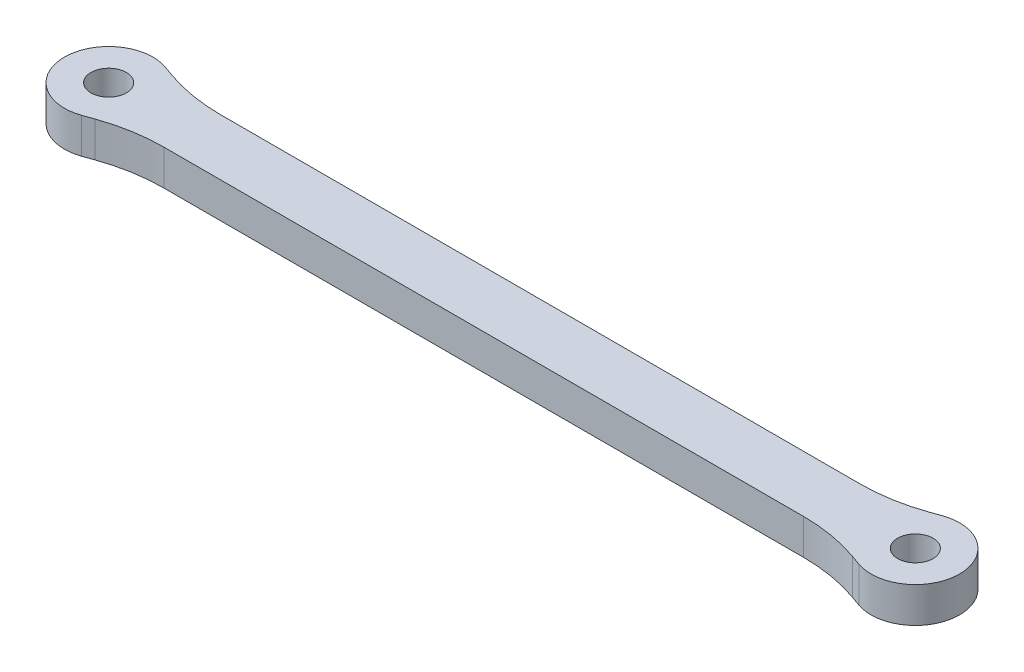
from build123d import *

# Parameters (mm, degrees)
SKETCH1_R           = 1
BOSS_EXTRUDE2_DEPTH = 2
FILLET2_R           = 10


with BuildPart() as part:
    # Sketch1 → Boss-Extrude2 (new body)
    with BuildSketch(Plane(origin=(0, 0, 0), x_dir=(1, 0, 0), z_dir=(0, 1, 0))):
        with BuildLine():
            Line((0.833333333, 2.357022604), (3.0003558, 1.590864463))
            Line((3.0003558, 1.590864463), (42.4996442, 1.590864463))
            Line((42.4996442, 1.590864463), (44.666666667, 2.357022604))
            ThreePointArc((44.666666667, 2.357022604), (48, 0), (44.666666667, -2.357022604))
            Line((44.666666667, -2.357022604), (42.4996442, -1.590864463))
            Line((42.4996442, -1.590864463), (3.0003558, -1.590864463))
            Line((3.0003558, -1.590864463), (0.833333333, -2.357022604))
            ThreePointArc((0.833333333, -2.357022604), (-2.5, 0), (0.833333333, 2.357022604))
        make_face()
        Circle(SKETCH1_R, mode=Mode.SUBTRACT)
        with Locations((45.5, 0)):
            Circle(SKETCH1_R, mode=Mode.SUBTRACT)
    extrude(amount=BOSS_EXTRUDE2_DEPTH)

    # Fillet2
    fillet2_edges = [part.edges().sort_by_distance(p)[0] for p in [
        (42.4996442, 1, -1.590864463),
        (42.4996442, 1, 1.590864463),
        (3.0003558, 1, 1.590864463),
        (3.0003558, 1, -1.590864463),
    ]]
    fillet(fillet2_edges, radius=FILLET2_R)


solid = part.part
